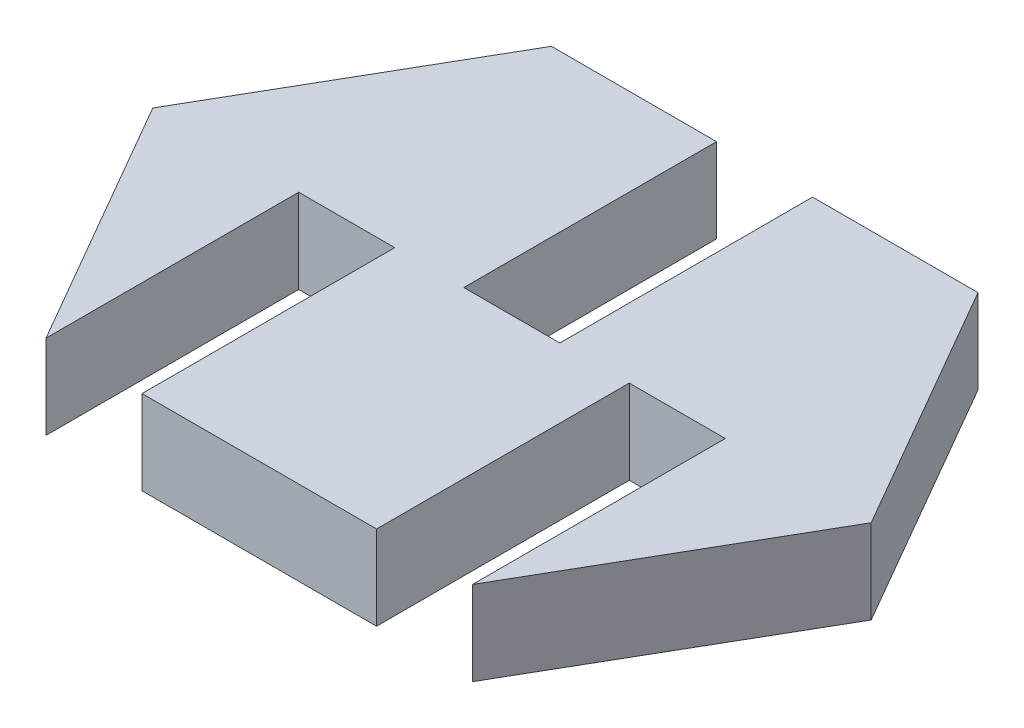
from build123d import *

# Parameters (mm, degrees)
BOSS_EXTRUDE1_DEPTH = 2.5
SKETCH5_W           = 2.85
SKETCH5_H           = 2.5
CUT_EXTRUDE2_DEPTH  = 7.5
SKETCH6_W           = 2.85
SKETCH6_H           = 2.5
CUT_EXTRUDE3_DEPTH  = 7.5
SKETCH7_W           = 2.85
SKETCH7_H           = 2.5
CUT_EXTRUDE4_DEPTH  = 7.5


with BuildPart() as part:
    # Sketch1 → Boss-Extrude1 (new body)
    with BuildSketch(Plane(origin=(0, 0, 0), x_dir=(1, 0, 0), z_dir=(0, 1, 0))):
        Polygon((8.581310361, -0.009375041), (4.251183342, 7.490624959), (-8.409070695, 7.490624959), (-12.739197714, -0.009375041), (-8.409070695, -7.509375041), (4.251183342, -7.509375041), align=None)
    extrude(amount=BOSS_EXTRUDE1_DEPTH)

    # Sketch5 → Cut-Extrude2 (cut)
    with BuildSketch(Plane.XY.offset(7.509375041)):
        with Locations((-6.984070695, 1.25)):
            Rectangle(SKETCH5_W, SKETCH5_H)
    extrude(amount=-CUT_EXTRUDE2_DEPTH, mode=Mode.SUBTRACT)

    # Sketch6 → Cut-Extrude3 (cut)
    with BuildSketch(Plane.XY.offset(7.509375041)):
        with Locations((2.826183342, 1.25)):
            Rectangle(SKETCH6_W, SKETCH6_H)
    extrude(amount=-CUT_EXTRUDE3_DEPTH, mode=Mode.SUBTRACT)

    # Sketch7 → Cut-Extrude4 (cut)
    with BuildSketch(Plane(origin=(0, 0, -7.490624959), x_dir=(-1, 0, 0), z_dir=(0, 0, -1))):
        with Locations((2.083816658, 1.25)):
            Rectangle(SKETCH7_W, SKETCH7_H)
    extrude(amount=-CUT_EXTRUDE4_DEPTH, mode=Mode.SUBTRACT)


solid = part.part
